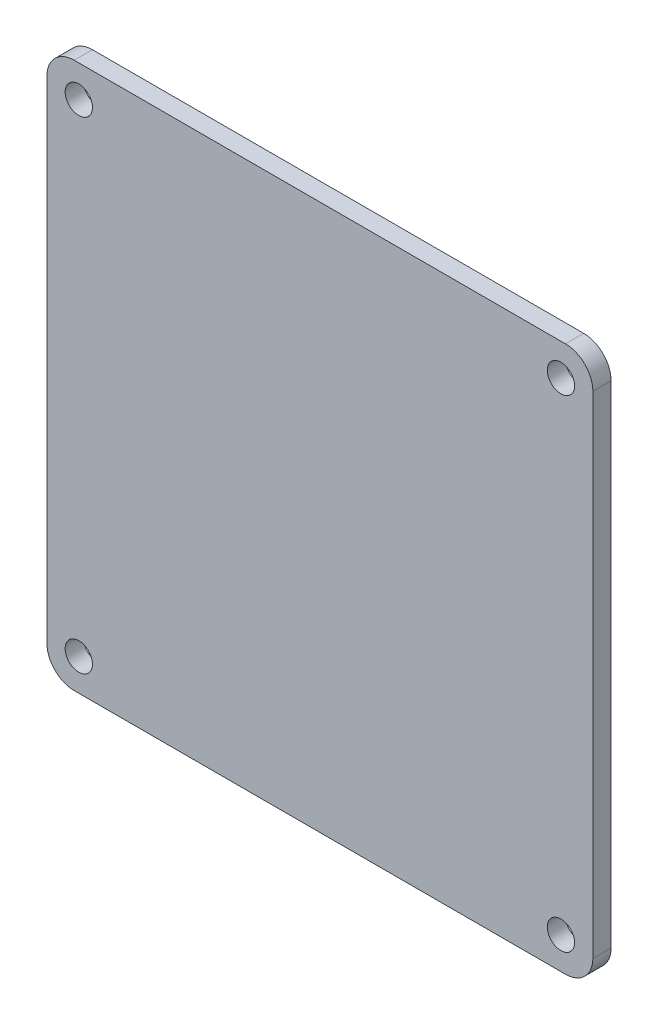
from build123d import *

# Parameters (mm, degrees)
SKETCH1_W           = 59.9
SKETCH1_H           = 59.9
SKETCH1_R           = 1.5
BOSS_EXTRUDE1_DEPTH = 2
FILLET1_R           = 3


with BuildPart() as part:
    # Sketch1 → Boss-Extrude1 (new body)
    with BuildSketch(Plane.XY):
        Rectangle(SKETCH1_W, SKETCH1_H)
        with Locations((-26.45, -26.45)):
            Circle(SKETCH1_R, mode=Mode.SUBTRACT)
        with Locations((26.45, -26.45)):
            Circle(SKETCH1_R, mode=Mode.SUBTRACT)
        with Locations((-26.45, 26.45)):
            Circle(SKETCH1_R, mode=Mode.SUBTRACT)
        with Locations((26.45, 26.45)):
            Circle(SKETCH1_R, mode=Mode.SUBTRACT)
    extrude(amount=BOSS_EXTRUDE1_DEPTH)

    # Fillet1
    fillet1_edges = [part.edges().sort_by_distance(p)[0] for p in [
        (29.95, -29.95, 1),
        (-29.95, -29.95, 1),
        (-29.95, 29.95, 1),
        (29.95, 29.95, 1),
    ]]
    fillet(fillet1_edges, radius=FILLET1_R)


solid = part.part
